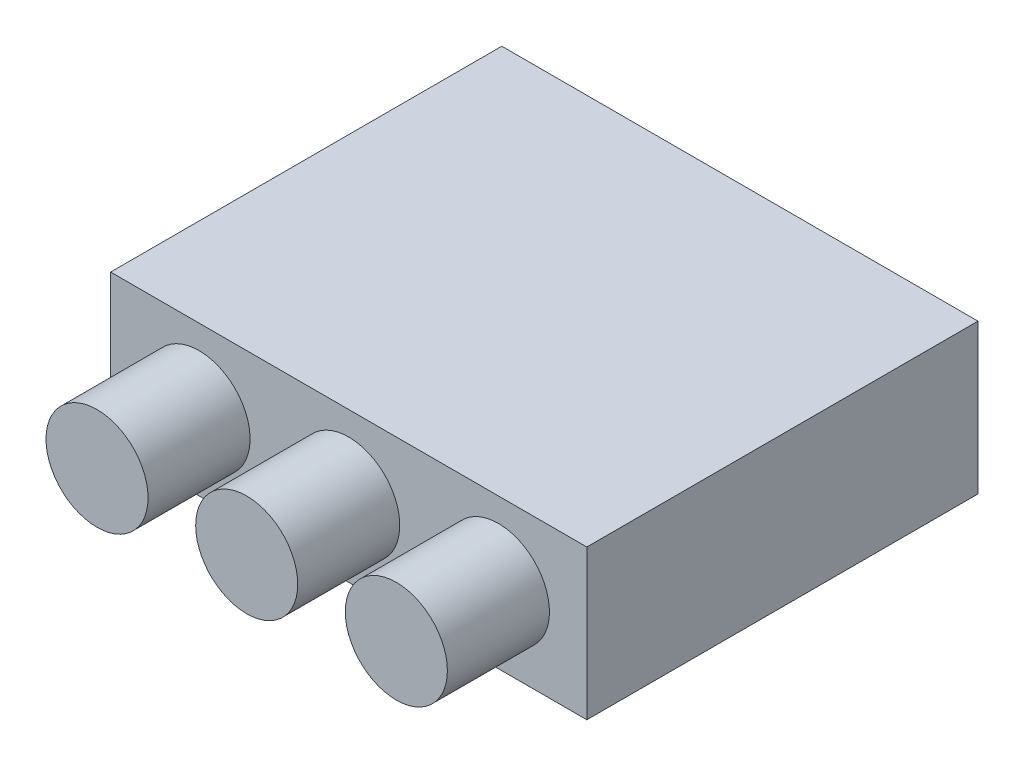
from build123d import *

# Parameters (mm, degrees)
SKETCH_1_W          = 70
SKETCH_1_H          = 57.5
EXTRUDE_1_DEPTH     = 22
SKETCH_2_R          = 7.5
EXTRUDE_2_DEPTH     = 15
SKETCH_3_R          = 1
CUT_EXTRUDE_1_DEPTH = 5


with BuildPart() as part:
    # 草图1 → 凸台-拉伸1 (new body)
    with BuildSketch(Plane(origin=(0, 0, 0), x_dir=(1, 0, 0), z_dir=(0, 1, 0))):
        Rectangle(SKETCH_1_W, SKETCH_1_H)
    extrude(amount=EXTRUDE_1_DEPTH)

    # 草图2 → 凸台-拉伸2 (add)
    with BuildSketch(Plane.XY.offset(28.75)):
        with Locations((-22, 11)):
            Circle(SKETCH_2_R)
        with Locations((0, 11)):
            Circle(SKETCH_2_R)
        with Locations((22, 11)):
            Circle(SKETCH_2_R)
    extrude(amount=EXTRUDE_2_DEPTH)

    # 草图3 → 切除-拉伸1 (cut)
    with BuildSketch(Plane.XZ):
        with Locations((-32, 25)):
            Circle(SKETCH_3_R)
        with Locations((-32, -25)):
            Circle(SKETCH_3_R)
        with Locations((32, -25)):
            Circle(SKETCH_3_R)
        with Locations((32, 25)):
            Circle(SKETCH_3_R)
    extrude(amount=-CUT_EXTRUDE_1_DEPTH, mode=Mode.SUBTRACT)


solid = part.part
